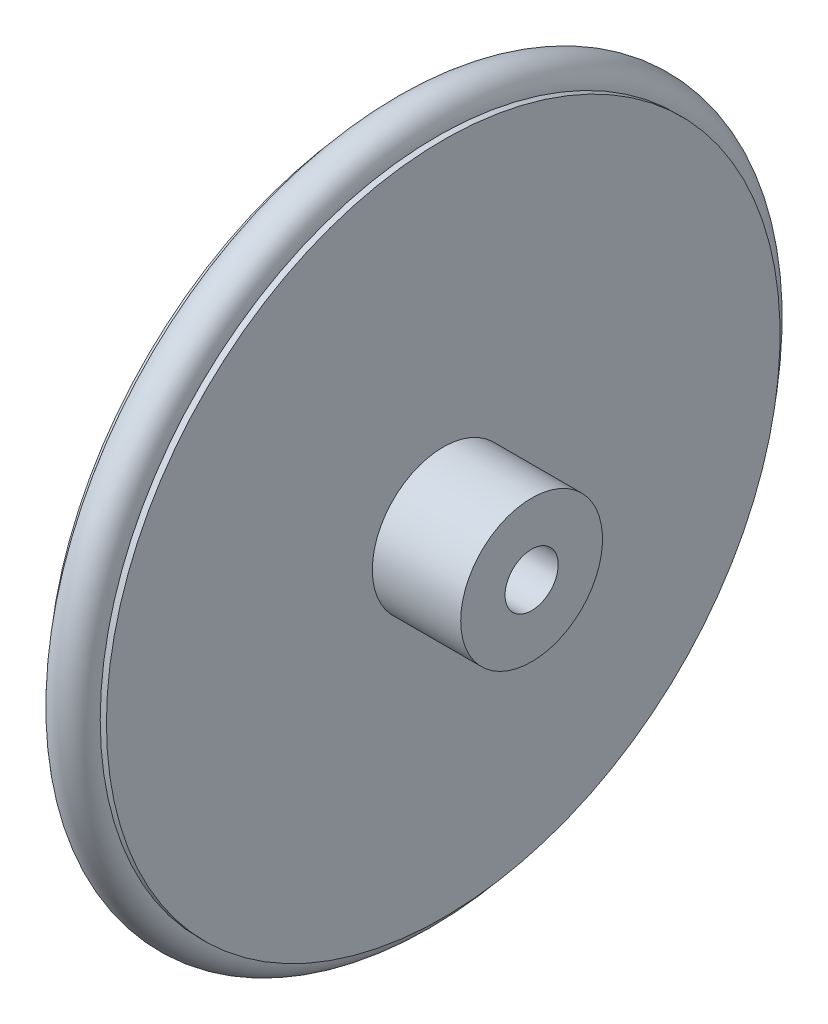
from build123d import *

# Parameters (mm, degrees)
ESQUISSE2_R             = 3
ENL_V_MAT_EXTRU_1_DEPTH = 17.57
ESQUISSE5_R             = 2.5


with BuildPart() as part:
    # Esquisse1 → Révolution1 (revolve)
    with BuildSketch(Plane.XY):
        Polygon((0, 0), (16.57, 0), (16.57, 8), (6.6, 8), (6.6, 38), (5.9, 38), (5.9, 35), (0.7, 35), (0.7, 38), (0, 38), align=None)
    revolve(axis=Axis((-19.945085304, 0, 0), (1, 0, 0)))

    # Esquisse2 → Enlèv. mat.-Extru.1 (cut, through all)
    with BuildSketch(Plane(origin=(16.57, 0, 0), x_dir=(0, 0, -1), z_dir=(1, 0, 0))):
        Circle(ESQUISSE2_R)
    extrude(amount=-ENL_V_MAT_EXTRU_1_DEPTH, mode=Mode.SUBTRACT)


with BuildPart() as body_2:
    # Balayage1: sweep along a path in Esquisse4
    with BuildLine(Plane(origin=(3.3, 0, 0), x_dir=(0, 0, -1), z_dir=(1, 0, 0))) as balayage1_path:
        CenterArc((0, 0), 38.5, 0, 360)
    # Esquisse5 → Balayage1 (sweep)
    with BuildSketch(Plane.XY):
        with Locations((3.3, 38)):
            Circle(ESQUISSE5_R)
    sweep(path=balayage1_path.line)


solid = Compound([part.part, body_2.part])
